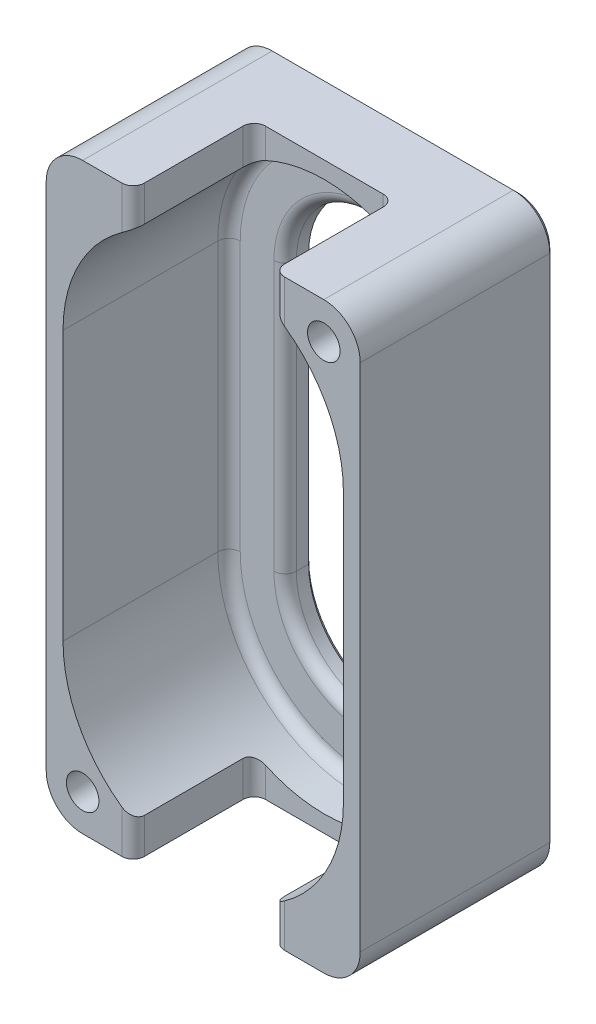
from build123d import *

# Parameters (mm, degrees)
SKETCH1_W                                       = 56
SKETCH1_H                                       = 104
BOSS_EXTRUDE1_DEPTH                             = 29.6
SKETCH2_W                                       = 56
SKETCH2_H                                       = 104
BOSS_EXTRUDE2_DEPTH                             = 5
FILLET1_R                                       = 2
SKETCH3_W                                       = 25
SKETCH3_H                                       = 21.6
CUT_EXTRUDE1_DEPTH                              = 53
CUT_EXTRUDE1_DEPTH_BACK                         = 53
FILLET2_R                                       = 2
FILLET3_R                                       = 6.5
CSK_FOR_M5_FLAT_HEAD_MACHINE_SCREW1_D           = 5.8
CSK_FOR_M5_FLAT_HEAD_MACHINE_SCREW1_CSINK_D     = 10.4
CSK_FOR_M5_FLAT_HEAD_MACHINE_SCREW1_CSINK_ANGLE = 90
CHAMFER1_SIZE                                   = 0.8


with BuildPart() as part:
    # Sketch1 → Boss-Extrude1 (new body)
    with BuildSketch(Plane.XY):
        Rectangle(SKETCH1_W, SKETCH1_H)
        with BuildLine():
            Line((25, 24), (25, -24))
            ThreePointArc((25, -24), (0, -49), (-25, -24))
            Line((-25, -24), (-25, 24))
            ThreePointArc((-25, 24), (0, 49), (25, 24))
        make_face(mode=Mode.SUBTRACT)
    extrude(amount=BOSS_EXTRUDE1_DEPTH)

    # Sketch2 → Boss-Extrude2 (add)
    with BuildSketch(Plane(origin=(0, 0, 0), x_dir=(-1, 0, 0), z_dir=(0, 0, -1))):
        Rectangle(SKETCH2_W, SKETCH2_H)
        with BuildLine():
            Line((-15, 24), (-15, -24))
            ThreePointArc((-15, -24), (0, -39), (15, -24))
            Line((15, -24), (15, 24))
            ThreePointArc((15, 24), (0, 39), (-15, 24))
        make_face(mode=Mode.SUBTRACT)
    extrude(amount=BOSS_EXTRUDE2_DEPTH)

    # Fillet1
    fillet1_edges = [part.edges().sort_by_distance(p)[0] for p in [
        (0, 49, 0),
        (-25, 0, 0),
        (0, -49, 0),
        (25, 0, 0),
        (0, 39, 0),
        (15, 0, 0),
        (0, -39, 0),
        (-15, 0, 0),
    ]]
    fillet(fillet1_edges, radius=FILLET1_R)

    # Sketch3 → Cut-Extrude1 (cut, two sides)
    with BuildSketch(Plane(origin=(0, 0, 0), x_dir=(1, 0, 0), z_dir=(0, 1, 0))) as cut_extrude1_sk:
        with Locations((0, -18.8)):
            Rectangle(SKETCH3_W, SKETCH3_H)
    extrude(amount=CUT_EXTRUDE1_DEPTH, mode=Mode.SUBTRACT)
    extrude(cut_extrude1_sk.sketch, amount=-CUT_EXTRUDE1_DEPTH_BACK, mode=Mode.SUBTRACT)

    # Fillet2
    fillet2_edges = [part.edges().sort_by_distance(p)[0] for p in [
        (-12.5, 48.825317547, 29.6),
        (-12.5, 48.825317547, 8),
        (12.5, 48.825317547, 8),
        (12.5, 48.825317547, 29.6),
        (-12.5, -48.825317547, 29.6),
        (-12.5, -48.825317547, 8),
        (12.5, -48.825317547, 8),
        (12.5, -48.825317547, 29.6),
    ]]
    fillet(fillet2_edges, radius=FILLET2_R)

    # Fillet3
    fillet3_edges = [part.edges().sort_by_distance(p)[0] for p in [
        (28, -52, 12.3),
        (-28, -52, 12.3),
        (-28, 52, 12.3),
        (28, 52, 12.3),
    ]]
    fillet(fillet3_edges, radius=FILLET3_R)

    # CSK for M5 Flat Head Machine Screw1 (through all)
    with Locations(Plane(origin=(21.5, 45.5, -5), x_dir=(-1, 0, 0), z_dir=(0, 0, -1))):
        with Locations((0, 0), (43, -91)):
            CounterSinkHole(CSK_FOR_M5_FLAT_HEAD_MACHINE_SCREW1_D / 2, CSK_FOR_M5_FLAT_HEAD_MACHINE_SCREW1_CSINK_D / 2, counter_sink_angle=CSK_FOR_M5_FLAT_HEAD_MACHINE_SCREW1_CSINK_ANGLE)

    # Chamfer1
    chamfer1_edges = [part.edges().sort_by_distance(p)[0] for p in [
        (-28, 0, -5),
        (0, 52, -5),
        (28, 0, -5),
        (0, -52, -5),
        (26.096194078, -50.096194078, -5),
        (26.096194078, 50.096194078, -5),
        (-26.096194078, -50.096194078, -5),
        (-26.096194078, 50.096194078, -5),
        (0, 39, -5),
        (15, 0, -5),
        (0, -39, -5),
        (-15, 0, -5),
    ]]
    chamfer(chamfer1_edges, length=CHAMFER1_SIZE)


solid = part.part
